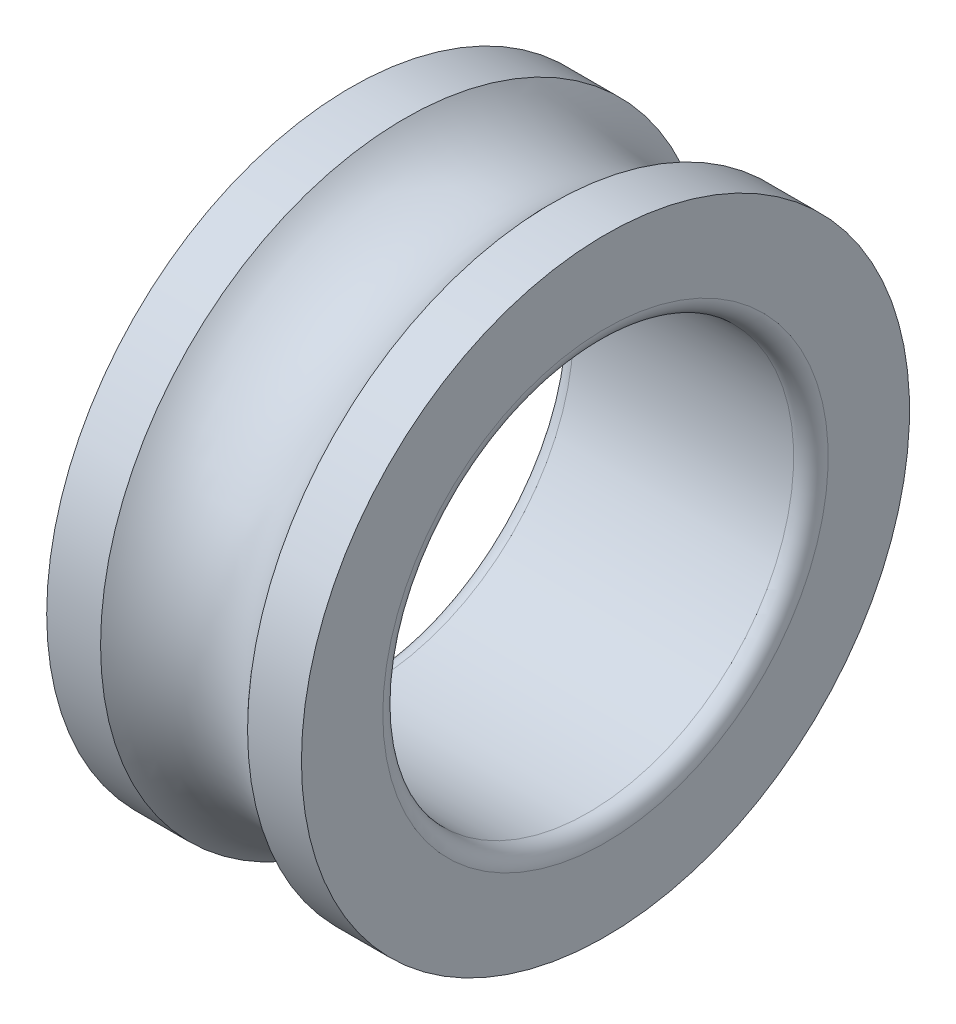
from build123d import *


with BuildPart() as part:
    # Sketch1 → Revolve1 (revolve)
    with BuildSketch(Plane.XY):
        with BuildLine():
            Line((-15.5, 37), (-8.94427191, 37))
            ThreePointArc((-8.94427191, 37), (0, 33), (8.94427191, 37))
            Line((8.94427191, 37), (15.5, 37))
            Line((15.5, 37), (15.5, 27.1))
            ThreePointArc((15.5, 27.1), (14.88492424, 25.61507576), (13.4, 25))
            Line((13.4, 25), (-13.4, 25))
            ThreePointArc((-13.4, 25), (-14.88492424, 25.61507576), (-15.5, 27.1))
            Line((-15.5, 27.1), (-15.5, 37))
        make_face()
    revolve(axis=Axis((-27.136752137, 0, 0), (1, 0, 0)))


solid = part.part
